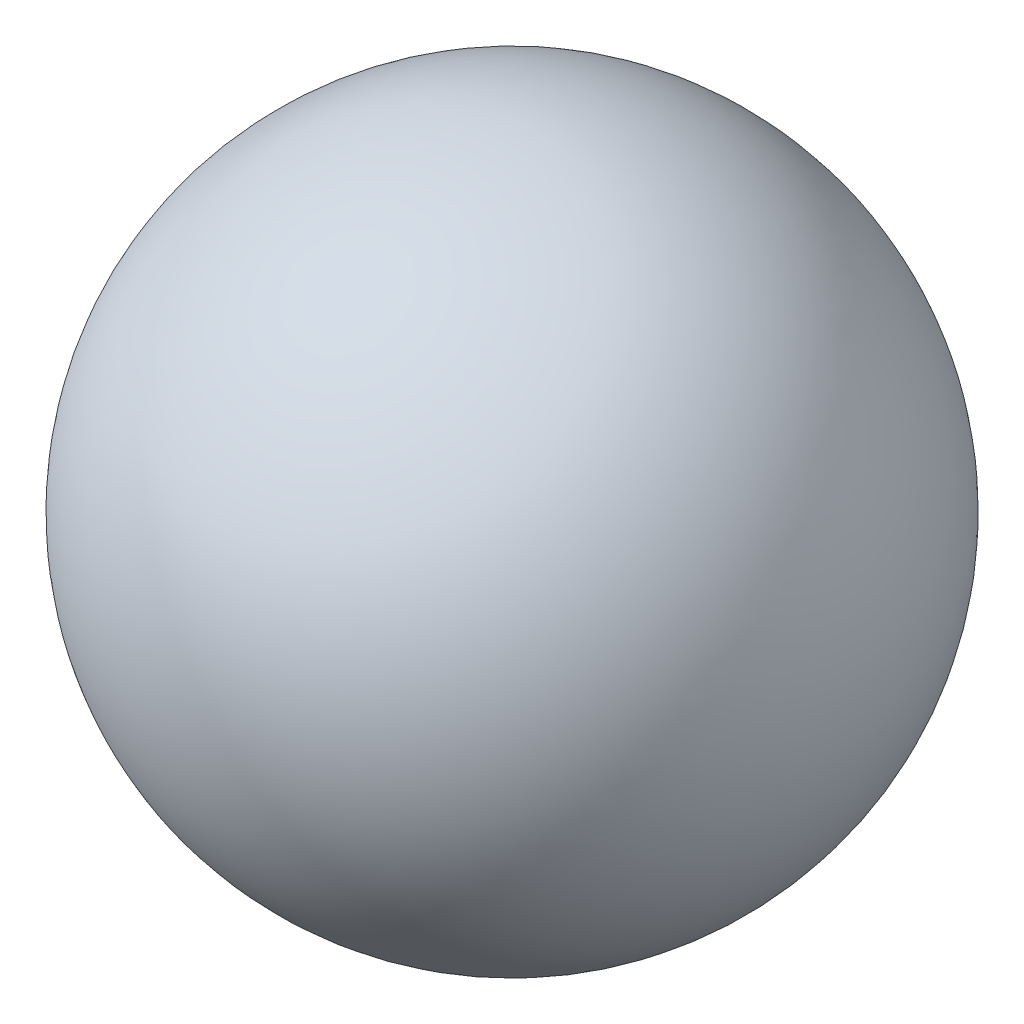
from build123d import *


with BuildPart() as part:
    # Sketch2 → Revolve-Thin1 (revolve)
    with BuildSketch(Plane(origin=(0, 0, 0), x_dir=(1, 0, 0), z_dir=(0, 1, 0))):
        with BuildLine():
            ThreePointArc((0, -20.32), (-20.32, 0), (0, 20.32))
            Line((0, 20.32), (0, 17.78))
            ThreePointArc((0, 17.78), (-17.78, 0), (0, -17.78))
            Line((0, -17.78), (0, -20.32))
        make_face()
    revolve(axis=Axis((0, 0, 1000), (0, 0, -1)))


solid = part.part
